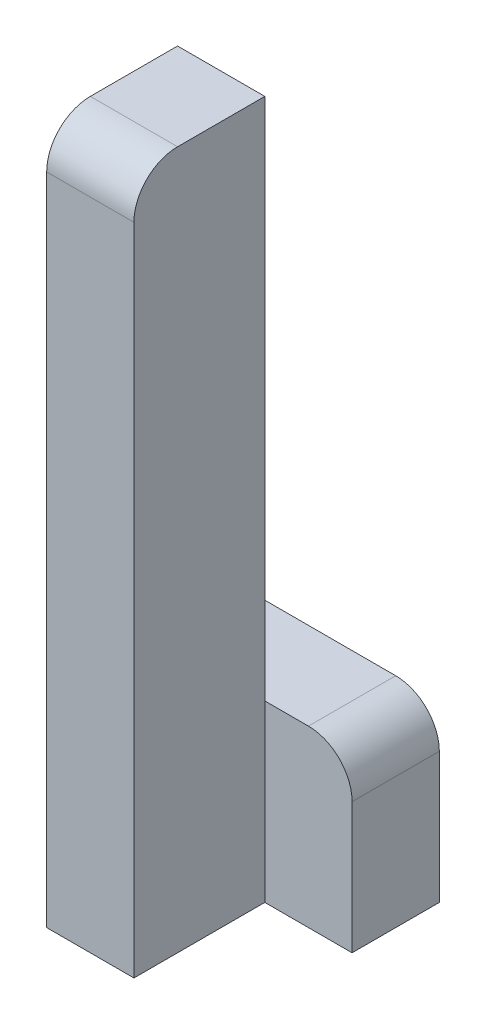
from build123d import *

# Parameters (mm, degrees)
SKETCH1_W           = 20
SKETCH1_H           = 160
BOSS_EXTRUDE1_DEPTH = 30
SKETCH2_W           = 40
SKETCH2_H           = 40
BOSS_EXTRUDE2_DEPTH = 20
FILLET1_R           = 10


with BuildPart() as part:
    # Sketch1 → Boss-Extrude1 (new body)
    with BuildSketch(Plane.XY):
        with Locations((-20, -80)):
            Rectangle(SKETCH1_W, SKETCH1_H)
    extrude(amount=BOSS_EXTRUDE1_DEPTH)

    # Sketch2 → Boss-Extrude2 (add)
    with BuildSketch(Plane.XY):
        with Locations((-10, -140)):
            Rectangle(SKETCH2_W, SKETCH2_H)
    extrude(amount=-BOSS_EXTRUDE2_DEPTH)

    # Fillet1
    fillet1_edges = [part.edges().sort_by_distance(p)[0] for p in [
        (10, -120, -10),
        (-20, 0, 30),
    ]]
    fillet(fillet1_edges, radius=FILLET1_R)


solid = part.part
